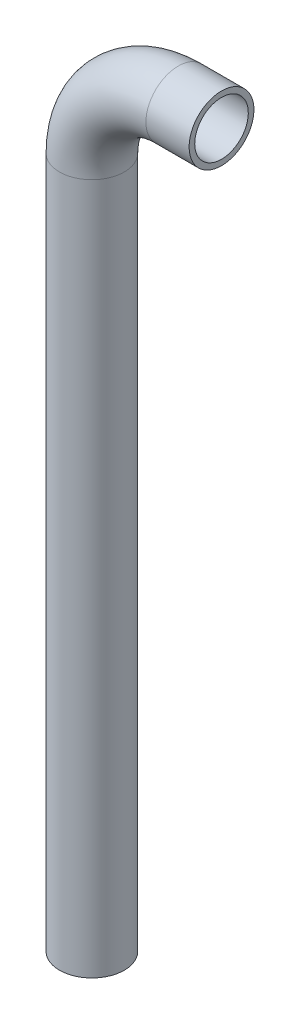
from build123d import *

# Parameters (mm, degrees)
SKETCH1_R   = 9.525
SKETCH1_R_2 = 7.874


with BuildPart() as part:
    # Sweep1: sweep along a path in Sketch2
    with BuildLine(Plane.XY) as sweep1_path:
        Line((0, 0), (0, 203.2))
        ThreePointArc((0, 203.2), (7.439487758, 221.160512242), (25.4, 228.6))
        Line((25.4, 228.6), (38.1, 228.6))
    # Sketch1 → Sweep1 (sweep)
    with BuildSketch(Plane(origin=(0, 0, 0), x_dir=(1, 0, 0), z_dir=(0, 1, 0))):
        Circle(SKETCH1_R)
        Circle(SKETCH1_R_2, mode=Mode.SUBTRACT)
    sweep(path=sweep1_path.line)


solid = part.part
